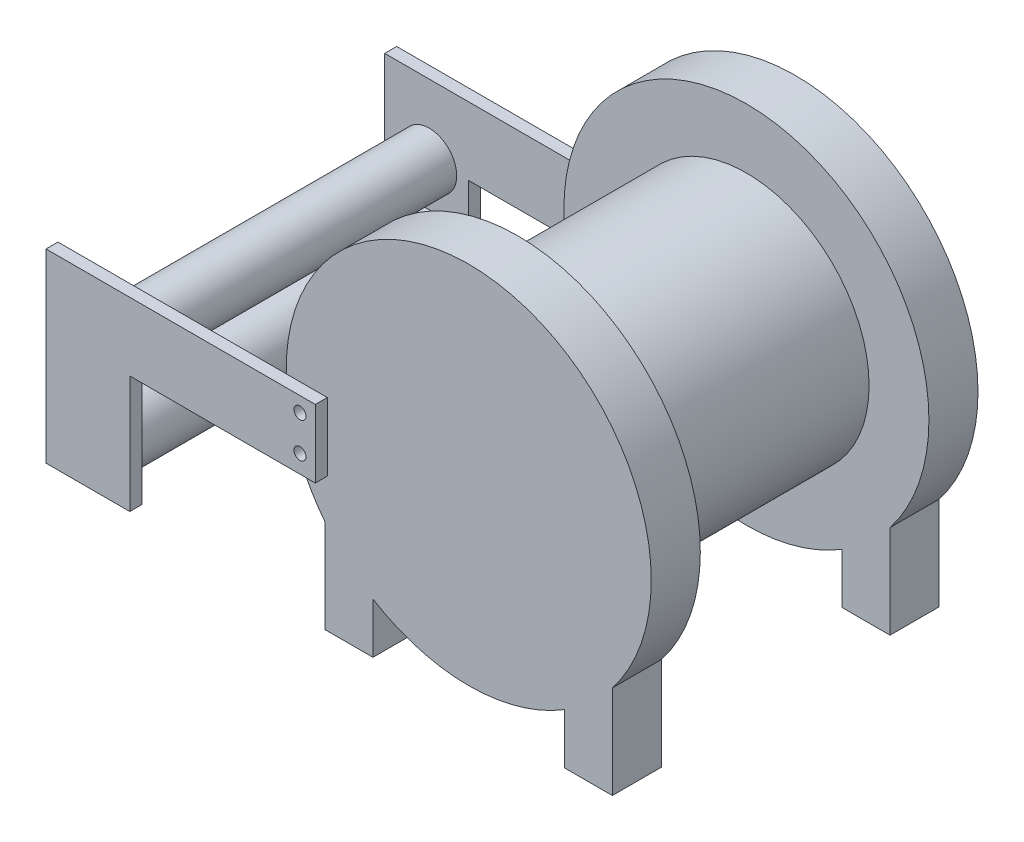
from build123d import *

# Parameters (mm, degrees)
SKETCH1_R           = 102.5
BOSS_EXTRUDE1_DEPTH = 41
BOSS_EXTRUDE2_START = 41
SKETCH1_3_R         = 102.5
BOSS_EXTRUDE2_DEPTH = 191
BOSS_EXTRUDE3_START = 232
SKETCH1_4_R         = 102.5
BOSS_EXTRUDE3_DEPTH = 41
SKETCH3_R           = 27.5
SKETCH3_R_2         = 23
SKETCH3_R_3         = 5
BOSS_EXTRUDE4_DEPTH = 10
SKETCH3_3_R         = 23
SKETCH3_3_R_2       = 27.5
BOSS_EXTRUDE5_DEPTH = 273


with BuildPart() as part:
    # Sketch1 → Boss-Extrude1 (new body)
    with BuildSketch(Plane.XY):
        with BuildLine():
            Line((120, 77.892348876), (120, 0))
            Line((120, 0), (80, 0))
            Line((80, 0), (80, 42.168378274))
            ThreePointArc((80, 42.168378274), (0, 19.5), (-80, 42.168378274))
            Line((-80, 42.168378274), (-80, 0))
            Line((-80, 0), (-120, 0))
            Line((-120, 0), (-120, 77.892348876))
            ThreePointArc((-120, 77.892348876), (0, 324.5), (120, 77.892348876))
        make_face()
        with Locations((0, 172)):
            Circle(SKETCH1_R, mode=Mode.SUBTRACT)
        with Locations((0, 172)):
            Circle(SKETCH1_R)
    extrude(amount=BOSS_EXTRUDE1_DEPTH)

    # Sketch1_3 → Boss-Extrude2 (add)
    with BuildSketch(Plane.XY.offset(BOSS_EXTRUDE2_START)):
        with Locations((0, 172)):
            Circle(SKETCH1_3_R)
    extrude(amount=BOSS_EXTRUDE2_DEPTH)

    # Sketch1_4 → Boss-Extrude3 (add)
    with BuildSketch(Plane.XY.offset(BOSS_EXTRUDE3_START)):
        with BuildLine():
            Line((120, 77.892348876), (120, 0))
            Line((120, 0), (80, 0))
            Line((80, 0), (80, 42.168378274))
            ThreePointArc((80, 42.168378274), (0, 19.5), (-80, 42.168378274))
            Line((-80, 42.168378274), (-80, 0))
            Line((-80, 0), (-120, 0))
            Line((-120, 0), (-120, 77.892348876))
            ThreePointArc((-120, 77.892348876), (0, 324.5), (120, 77.892348876))
        make_face()
        with Locations((0, 172)):
            Circle(SKETCH1_4_R, mode=Mode.SUBTRACT)
        with Locations((0, 172)):
            Circle(SKETCH1_4_R)
    extrude(amount=BOSS_EXTRUDE3_DEPTH)

    # Sketch3 → Boss-Extrude4 (add)
    with BuildSketch(Plane.XY):
        Polygon((-273.172788599, 112), (-118.172788599, 112), (-118.172788599, 168.9), (-273.172788599, 168.9), (-343.172788599, 168.9), (-343.172788599, 13.9), (-273.172788599, 13.9), align=None)
        with Locations((-306, 46.9)):
            Circle(SKETCH3_R, mode=Mode.SUBTRACT)
        with Locations((-306, 110.4)):
            Circle(SKETCH3_R_2, mode=Mode.SUBTRACT)
        with Locations((-131, 127)):
            Circle(SKETCH3_R_3, mode=Mode.SUBTRACT)
        with Locations((-131, 156.4)):
            Circle(SKETCH3_R_3, mode=Mode.SUBTRACT)
        with Locations((-306, 46.9)):
            Circle(SKETCH3_R)
        with Locations((-306, 110.4)):
            Circle(SKETCH3_R_2)
    boss_extrude4 = extrude(amount=-BOSS_EXTRUDE4_DEPTH)

    # Mirror1: Boss-Extrude4 across plane
    add(boss_extrude4.mirror(Plane(origin=(0, 0, 136.5), x_dir=(1, 0, 0), z_dir=(0, 0, -1))))

    # Sketch3_3 → Boss-Extrude5 (add)
    with BuildSketch(Plane.XY):
        with Locations((-306, 110.4)):
            Circle(SKETCH3_3_R)
        with Locations((-306, 46.9)):
            Circle(SKETCH3_3_R_2)
    extrude(amount=BOSS_EXTRUDE5_DEPTH)


solid = part.part
